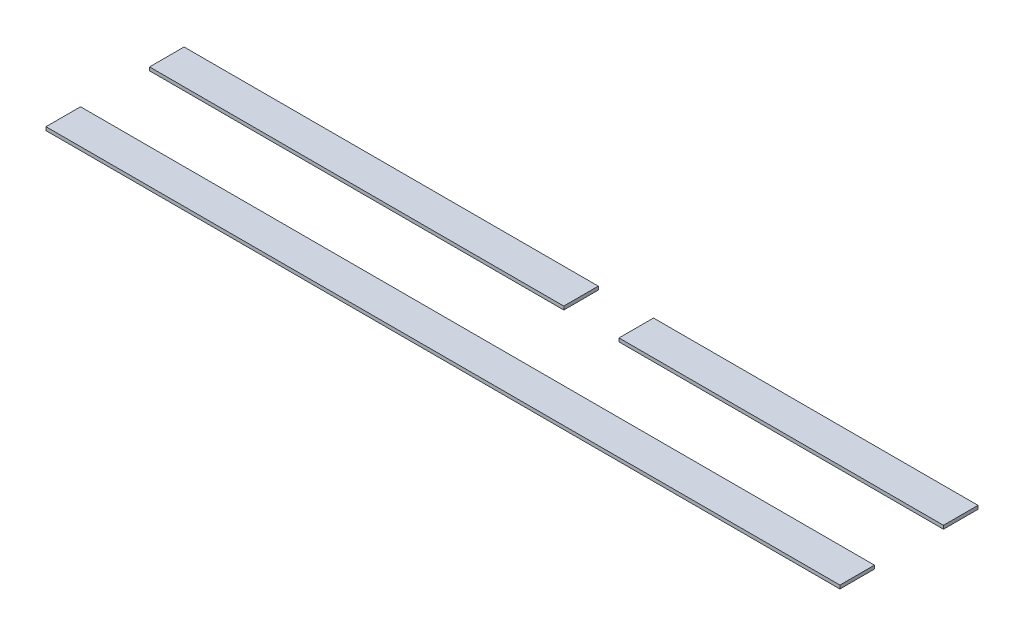
from build123d import *

# Parameters (mm, degrees)
SKETCH1_W             = 230
SKETCH1_H             = 10
BOSS_EXTRUDE1_DEPTH   = 1
SKETCH1_W_2           = 94
BOSS_EXTRUDE1_2_DEPTH = 1
SKETCH1_W_3           = 120
BOSS_EXTRUDE1_3_DEPTH = 1


with BuildPart() as part:
    # Sketch1 → Boss-Extrude1 (new body)
    with BuildSketch(Plane(origin=(0, 0, 0), x_dir=(1, 0, 0), z_dir=(0, 1, 0))):
        with Locations((115, 5)):
            Rectangle(SKETCH1_W, SKETCH1_H)
    extrude(amount=BOSS_EXTRUDE1_DEPTH)


with BuildPart() as body_2:
    # Sketch1 → Boss-Extrude1 2 (new body)
    with BuildSketch(Plane(origin=(0, 0, 0), x_dir=(1, 0, 0), z_dir=(0, 1, 0))):
        with Locations((183, 35)):
            Rectangle(SKETCH1_W_2, SKETCH1_H)
    extrude(amount=BOSS_EXTRUDE1_2_DEPTH)


with BuildPart() as body_3:
    # Sketch1 → Boss-Extrude1 3 (new body)
    with BuildSketch(Plane(origin=(0, 0, 0), x_dir=(1, 0, 0), z_dir=(0, 1, 0))):
        with Locations((60, 35)):
            Rectangle(SKETCH1_W_3, SKETCH1_H)
    extrude(amount=BOSS_EXTRUDE1_3_DEPTH)


solid = Compound([part.part, body_2.part, body_3.part])
